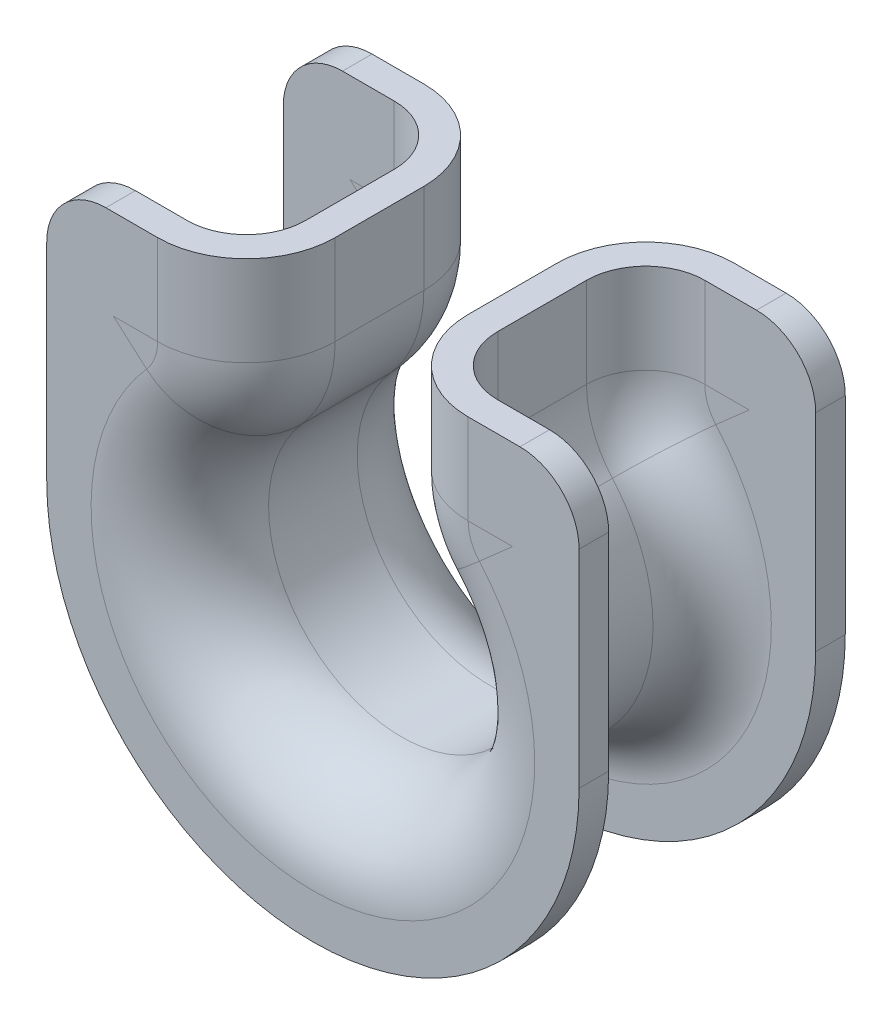
from build123d import *

# Parameters (mm, degrees)
BOSS_EXTRUDE1_DEPTH = 2
FILLET1_R           = 4


with BuildPart() as part:
    # Sweep3: sweep along a path in Sketch1
    with BuildLine(Plane.XY) as sweep3_path:
        Line((4.5, 18), (4.5, 11.9058809))
        ThreePointArc((4.5, 11.9058809), (5.08127088, 8.723900384), (6.75, 5.95294045))
        ThreePointArc((6.75, 5.95294045), (0, -9), (-6.75, 5.95294045))
        ThreePointArc((-6.75, 5.95294045), (-5.08127088, 8.723900384), (-4.5, 11.9058809))
        Line((-4.5, 11.9058809), (-4.5, 18))
    # Sketch2 → Sweep3 (sweep)
    with BuildSketch(Plane(origin=(-4.5, 18, 0), x_dir=(1, 0, 0), z_dir=(0, 1, 0))):
        with BuildLine():
            Line((0, 3), (0, -3))
            ThreePointArc((0, -3), (-1.757359313, -7.242640687), (-6, -9))
            Line((-6, -9), (-9, -9))
            Line((-9, -9), (-9, -7))
            Line((-9, -7), (-6, -7))
            ThreePointArc((-6, -7), (-3.171572875, -5.828427125), (-2, -3))
            Line((-2, -3), (-2, 3))
            ThreePointArc((-2, 3), (-3.171572875, 5.828427125), (-6, 7))
            Line((-6, 7), (-9, 7))
            Line((-9, 7), (-9, 9))
            Line((-9, 9), (-6, 9))
            ThreePointArc((-6, 9), (-1.757359313, 7.242640687), (0, 3))
        make_face()
    sweep(path=sweep3_path.line)

    # Sketch3 → Boss-Extrude1 (add)
    with BuildSketch(Plane.XY.offset(9)):
        with BuildLine():
            ThreePointArc((-13.5, 11.9058809), (-16.83745824, 6.363961031), (-18, 0))
            Line((-18, 0), (-18, 18))
            Line((-18, 18), (-13.5, 18))
            Line((-13.5, 18), (-13.5, 11.9058809))
        make_face()
        with BuildLine():
            Line((13.5, 18), (13.5, 11.9058809))
            ThreePointArc((13.5, 11.9058809), (16.83745824, 6.363961031), (18, 0))
            Line((18, 0), (18, 18))
            Line((18, 18), (13.5, 18))
        make_face()
    boss_extrude1 = extrude(amount=-BOSS_EXTRUDE1_DEPTH)

    # Mirror2: Boss-Extrude1 across plane
    add(boss_extrude1.mirror(Plane.XY))

    # Fillet1
    fillet1_edges = [part.edges().sort_by_distance(p)[0] for p in [
        (-18, 18, 8),
        (18, 18, 8),
        (-18, 18, -8),
        (18, 18, -8),
    ]]
    fillet(fillet1_edges, radius=FILLET1_R)


solid = part.part
